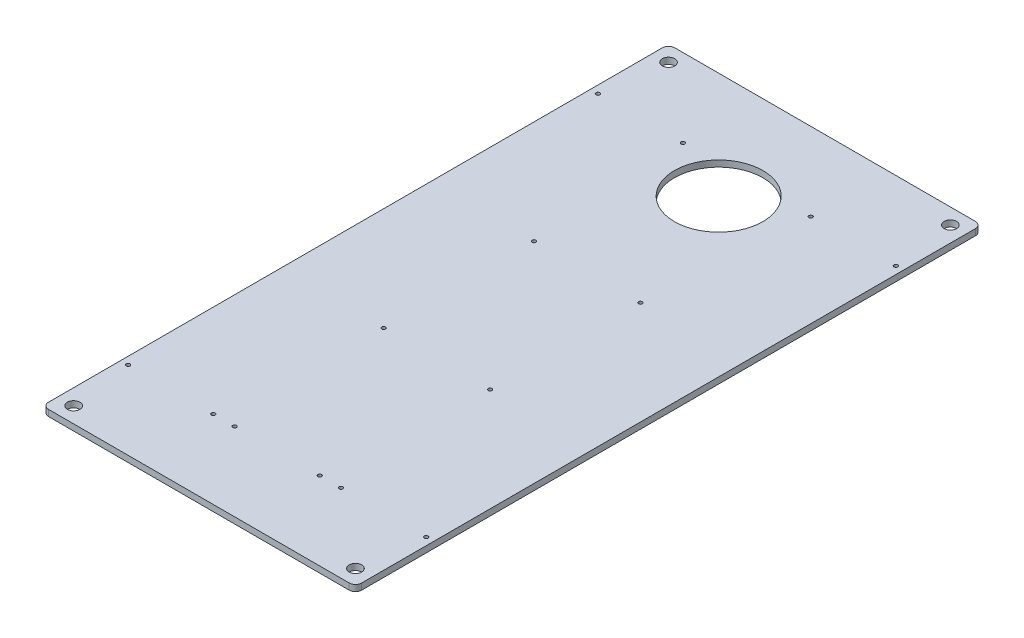
from build123d import *

# Parameters (mm, degrees)
SKETCH1_W                  = 500
SKETCH1_H                  = 1000
BOSS_EXTRUDE1_DEPTH        = 10
LO_BAT_XUONG_DAT_REACH     = 12
SKETCH2_R                  = 10
FILLET1_R                  = 10
CUT_EXTRUDE2_REACH         = 12
SKETCH3_R                  = 70.65
BAT_CHAN_DE_KHOP_NOI_REACH = 12
SKETCH4_R                  = 3
CUT_EXTRUDE3_REACH         = 12
SKETCH6_R                  = 3


with BuildPart() as part:
    # Sketch1 → Boss-Extrude1 (new body)
    with BuildSketch(Plane(origin=(0, 0, 0), x_dir=(1, 0, 0), z_dir=(0, 1, 0))):
        Rectangle(SKETCH1_W, SKETCH1_H)
    extrude(amount=BOSS_EXTRUDE1_DEPTH)

    # Sketch2 → lo bat xuong dat (cut, up to next)
    with BuildSketch(Plane(origin=(0, 10, 0), x_dir=(1, 0, 0), z_dir=(0, 1, 0)), mode=Mode.PRIVATE) as lo_bat_xuong_dat_sk1:
        with Locations((-225, 475)):
            Circle(SKETCH2_R)
    lo_bat_xuong_dat_tool1 = extrude(lo_bat_xuong_dat_sk1.sketch, amount=-LO_BAT_XUONG_DAT_REACH, mode=Mode.PRIVATE) & part.part
    add(lo_bat_xuong_dat_tool1.solids().sort_by_distance((-225, 10, -475))[0], mode=Mode.SUBTRACT)
    # Sketch2 → lo bat xuong dat (cut, up to next)
    with BuildSketch(Plane(origin=(0, 10, 0), x_dir=(1, 0, 0), z_dir=(0, 1, 0)), mode=Mode.PRIVATE) as lo_bat_xuong_dat_sk2:
        with Locations((225, 475)):
            Circle(SKETCH2_R)
    lo_bat_xuong_dat_tool2 = extrude(lo_bat_xuong_dat_sk2.sketch, amount=-LO_BAT_XUONG_DAT_REACH, mode=Mode.PRIVATE) & part.part
    add(lo_bat_xuong_dat_tool2.solids().sort_by_distance((225, 10, -475))[0], mode=Mode.SUBTRACT)
    # Sketch2 → lo bat xuong dat (cut, up to next)
    with BuildSketch(Plane(origin=(0, 10, 0), x_dir=(1, 0, 0), z_dir=(0, 1, 0)), mode=Mode.PRIVATE) as lo_bat_xuong_dat_sk3:
        with Locations((-225, -475)):
            Circle(SKETCH2_R)
    lo_bat_xuong_dat_tool3 = extrude(lo_bat_xuong_dat_sk3.sketch, amount=-LO_BAT_XUONG_DAT_REACH, mode=Mode.PRIVATE) & part.part
    add(lo_bat_xuong_dat_tool3.solids().sort_by_distance((-225, 10, 475))[0], mode=Mode.SUBTRACT)
    # Sketch2 → lo bat xuong dat (cut, up to next)
    with BuildSketch(Plane(origin=(0, 10, 0), x_dir=(1, 0, 0), z_dir=(0, 1, 0)), mode=Mode.PRIVATE) as lo_bat_xuong_dat_sk4:
        with Locations((225, -475)):
            Circle(SKETCH2_R)
    lo_bat_xuong_dat_tool4 = extrude(lo_bat_xuong_dat_sk4.sketch, amount=-LO_BAT_XUONG_DAT_REACH, mode=Mode.PRIVATE) & part.part
    add(lo_bat_xuong_dat_tool4.solids().sort_by_distance((225, 10, 475))[0], mode=Mode.SUBTRACT)

    # Fillet1
    fillet1_edges = [part.edges().sort_by_distance(p)[0] for p in [
        (250, 5, 500),
        (-250, 5, 500),
        (-250, 5, -500),
        (250, 5, -500),
    ]]
    fillet(fillet1_edges, radius=FILLET1_R)

    # Sketch3 → Cut-Extrude2 (cut, up to next)
    with BuildSketch(Plane(origin=(0, 10, 0), x_dir=(1, 0, 0), z_dir=(0, 1, 0)), mode=Mode.PRIVATE) as cut_extrude2_sk1:
        with Locations((0, 330)):
            Circle(SKETCH3_R)
    cut_extrude2_tool1 = extrude(cut_extrude2_sk1.sketch, amount=-CUT_EXTRUDE2_REACH, mode=Mode.PRIVATE) & part.part
    add(cut_extrude2_tool1.solids().sort_by_distance((0, 10, -330))[0], mode=Mode.SUBTRACT)

    # Sketch4 → bat chan de khop noi (cut, up to next)
    with BuildSketch(Plane(origin=(0, 10, 0), x_dir=(1, 0, 0), z_dir=(0, 1, 0)), mode=Mode.PRIVATE) as bat_chan_de_khop_noi_sk1:
        with Locations((-85, 120)):
            Circle(SKETCH4_R)
    bat_chan_de_khop_noi_tool1 = extrude(bat_chan_de_khop_noi_sk1.sketch, amount=-BAT_CHAN_DE_KHOP_NOI_REACH, mode=Mode.PRIVATE) & part.part
    add(bat_chan_de_khop_noi_tool1.solids().sort_by_distance((-85, 10, -120))[0], mode=Mode.SUBTRACT)
    # Sketch4 → bat chan de khop noi (cut, up to next)
    with BuildSketch(Plane(origin=(0, 10, 0), x_dir=(1, 0, 0), z_dir=(0, 1, 0)), mode=Mode.PRIVATE) as bat_chan_de_khop_noi_sk2:
        with Locations((85, 120)):
            Circle(SKETCH4_R)
    bat_chan_de_khop_noi_tool2 = extrude(bat_chan_de_khop_noi_sk2.sketch, amount=-BAT_CHAN_DE_KHOP_NOI_REACH, mode=Mode.PRIVATE) & part.part
    add(bat_chan_de_khop_noi_tool2.solids().sort_by_distance((85, 10, -120))[0], mode=Mode.SUBTRACT)
    # Sketch4 → bat chan de khop noi (cut, up to next)
    with BuildSketch(Plane(origin=(0, 10, 0), x_dir=(1, 0, 0), z_dir=(0, 1, 0)), mode=Mode.PRIVATE) as bat_chan_de_khop_noi_sk3:
        with Locations((85, -120)):
            Circle(SKETCH4_R)
    bat_chan_de_khop_noi_tool3 = extrude(bat_chan_de_khop_noi_sk3.sketch, amount=-BAT_CHAN_DE_KHOP_NOI_REACH, mode=Mode.PRIVATE) & part.part
    add(bat_chan_de_khop_noi_tool3.solids().sort_by_distance((85, 10, 120))[0], mode=Mode.SUBTRACT)
    # Sketch4 → bat chan de khop noi (cut, up to next)
    with BuildSketch(Plane(origin=(0, 10, 0), x_dir=(1, 0, 0), z_dir=(0, 1, 0)), mode=Mode.PRIVATE) as bat_chan_de_khop_noi_sk4:
        with Locations((-85, -120)):
            Circle(SKETCH4_R)
    bat_chan_de_khop_noi_tool4 = extrude(bat_chan_de_khop_noi_sk4.sketch, amount=-BAT_CHAN_DE_KHOP_NOI_REACH, mode=Mode.PRIVATE) & part.part
    add(bat_chan_de_khop_noi_tool4.solids().sort_by_distance((-85, 10, 120))[0], mode=Mode.SUBTRACT)

    # Sketch6 → Cut-Extrude3 (cut, up to next)
    with BuildSketch(Plane(origin=(0, 10, 0), x_dir=(1, 0, 0), z_dir=(0, 1, 0)), mode=Mode.PRIVATE) as cut_extrude3_sk1:
        with Locations((238, -375)):
            Circle(SKETCH6_R)
    cut_extrude3_tool1 = extrude(cut_extrude3_sk1.sketch, amount=-CUT_EXTRUDE3_REACH, mode=Mode.PRIVATE) & part.part
    add(cut_extrude3_tool1.solids().sort_by_distance((238, 10, 375))[0], mode=Mode.SUBTRACT)
    # Sketch6 → Cut-Extrude3 (cut, up to next)
    with BuildSketch(Plane(origin=(0, 10, 0), x_dir=(1, 0, 0), z_dir=(0, 1, 0)), mode=Mode.PRIVATE) as cut_extrude3_sk2:
        with Locations((102, -375)):
            Circle(SKETCH6_R)
    cut_extrude3_tool2 = extrude(cut_extrude3_sk2.sketch, amount=-CUT_EXTRUDE3_REACH, mode=Mode.PRIVATE) & part.part
    add(cut_extrude3_tool2.solids().sort_by_distance((102, 10, 375))[0], mode=Mode.SUBTRACT)
    # Sketch6 → Cut-Extrude3 (cut, up to next)
    with BuildSketch(Plane(origin=(0, 10, 0), x_dir=(1, 0, 0), z_dir=(0, 1, 0)), mode=Mode.PRIVATE) as cut_extrude3_sk3:
        with Locations((-102, -375)):
            Circle(SKETCH6_R)
    cut_extrude3_tool3 = extrude(cut_extrude3_sk3.sketch, amount=-CUT_EXTRUDE3_REACH, mode=Mode.PRIVATE) & part.part
    add(cut_extrude3_tool3.solids().sort_by_distance((-102, 10, 375))[0], mode=Mode.SUBTRACT)
    # Sketch6 → Cut-Extrude3 (cut, up to next)
    with BuildSketch(Plane(origin=(0, 10, 0), x_dir=(1, 0, 0), z_dir=(0, 1, 0)), mode=Mode.PRIVATE) as cut_extrude3_sk4:
        with Locations((-238, -375)):
            Circle(SKETCH6_R)
    cut_extrude3_tool4 = extrude(cut_extrude3_sk4.sketch, amount=-CUT_EXTRUDE3_REACH, mode=Mode.PRIVATE) & part.part
    add(cut_extrude3_tool4.solids().sort_by_distance((-238, 10, 375))[0], mode=Mode.SUBTRACT)
    # Sketch6 → Cut-Extrude3 (cut, up to next)
    with BuildSketch(Plane(origin=(0, 10, 0), x_dir=(1, 0, 0), z_dir=(0, 1, 0)), mode=Mode.PRIVATE) as cut_extrude3_sk5:
        with Locations((-238, 375)):
            Circle(SKETCH6_R)
    cut_extrude3_tool5 = extrude(cut_extrude3_sk5.sketch, amount=-CUT_EXTRUDE3_REACH, mode=Mode.PRIVATE) & part.part
    add(cut_extrude3_tool5.solids().sort_by_distance((-238, 10, -375))[0], mode=Mode.SUBTRACT)
    # Sketch6 → Cut-Extrude3 (cut, up to next)
    with BuildSketch(Plane(origin=(0, 10, 0), x_dir=(1, 0, 0), z_dir=(0, 1, 0)), mode=Mode.PRIVATE) as cut_extrude3_sk6:
        with Locations((-102, 375)):
            Circle(SKETCH6_R)
    cut_extrude3_tool6 = extrude(cut_extrude3_sk6.sketch, amount=-CUT_EXTRUDE3_REACH, mode=Mode.PRIVATE) & part.part
    add(cut_extrude3_tool6.solids().sort_by_distance((-102, 10, -375))[0], mode=Mode.SUBTRACT)
    # Sketch6 → Cut-Extrude3 (cut, up to next)
    with BuildSketch(Plane(origin=(0, 10, 0), x_dir=(1, 0, 0), z_dir=(0, 1, 0)), mode=Mode.PRIVATE) as cut_extrude3_sk7:
        with Locations((102, 375)):
            Circle(SKETCH6_R)
    cut_extrude3_tool7 = extrude(cut_extrude3_sk7.sketch, amount=-CUT_EXTRUDE3_REACH, mode=Mode.PRIVATE) & part.part
    add(cut_extrude3_tool7.solids().sort_by_distance((102, 10, -375))[0], mode=Mode.SUBTRACT)
    # Sketch6 → Cut-Extrude3 (cut, up to next)
    with BuildSketch(Plane(origin=(0, 10, 0), x_dir=(1, 0, 0), z_dir=(0, 1, 0)), mode=Mode.PRIVATE) as cut_extrude3_sk8:
        with Locations((238, 375)):
            Circle(SKETCH6_R)
    cut_extrude3_tool8 = extrude(cut_extrude3_sk8.sketch, amount=-CUT_EXTRUDE3_REACH, mode=Mode.PRIVATE) & part.part
    add(cut_extrude3_tool8.solids().sort_by_distance((238, 10, -375))[0], mode=Mode.SUBTRACT)
    # Sketch6 → Cut-Extrude3 (cut, up to next)
    with BuildSketch(Plane(origin=(0, 10, 0), x_dir=(1, 0, 0), z_dir=(0, 1, 0)), mode=Mode.PRIVATE) as cut_extrude3_sk9:
        with Locations((68, -375)):
            Circle(SKETCH6_R)
    cut_extrude3_tool9 = extrude(cut_extrude3_sk9.sketch, amount=-CUT_EXTRUDE3_REACH, mode=Mode.PRIVATE) & part.part
    add(cut_extrude3_tool9.solids().sort_by_distance((68, 10, 375))[0], mode=Mode.SUBTRACT)
    # Sketch6 → Cut-Extrude3 (cut, up to next)
    with BuildSketch(Plane(origin=(0, 10, 0), x_dir=(1, 0, 0), z_dir=(0, 1, 0)), mode=Mode.PRIVATE) as cut_extrude3_sk10:
        with Locations((-68, -375)):
            Circle(SKETCH6_R)
    cut_extrude3_tool10 = extrude(cut_extrude3_sk10.sketch, amount=-CUT_EXTRUDE3_REACH, mode=Mode.PRIVATE) & part.part
    add(cut_extrude3_tool10.solids().sort_by_distance((-68, 10, 375))[0], mode=Mode.SUBTRACT)


solid = part.part
